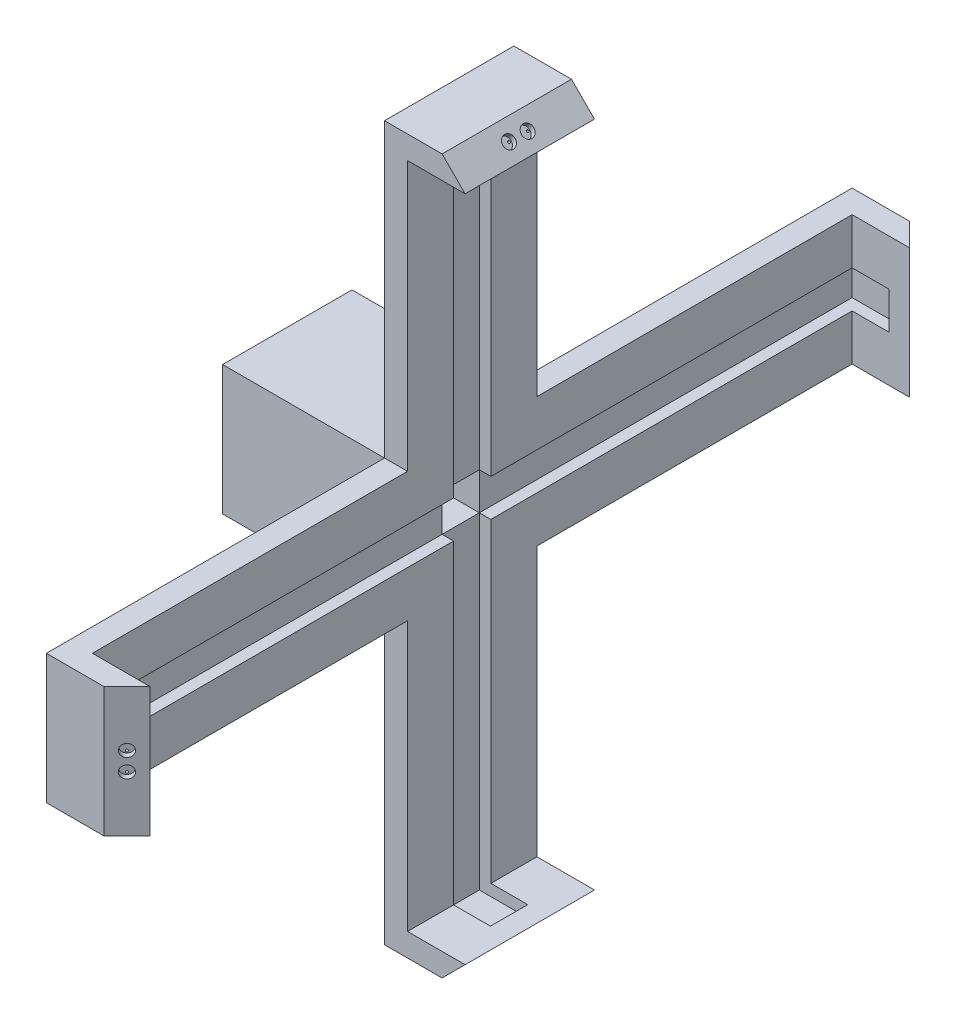
from build123d import *

# Parameters (mm, degrees)
SKETCH1_R            = 28.1
BOSS_EXTRUDE2_DEPTH  = 24
CUT_EXTRUDE2_DEPTH   = 21.5
SKETCH4_R            = 3
CUT_EXTRUDE3_DEPTH   = 9.5
SKETCH6_R            = 6.025
CUT_EXTRUDE4_DEPTH   = 6.2
SKETCH7_W            = 56.2
SKETCH7_H            = 56.2
BOSS_EXTRUDE3_DEPTH  = 56.2
SKETCH8_W            = 56.2
SKETCH8_H            = 56.2
BOSS_EXTRUDE4_DEPTH  = 14.14
SKETCH10_W           = 56.2
SKETCH10_H           = 56.2
BOSS_EXTRUDE5_DEPTH  = 10
SKETCH11_W           = 10
SKETCH11_H           = 56.2
BOSS_EXTRUDE6_DEPTH  = 146.9
SKETCH12_W           = 10
SKETCH12_H           = 56.2
BOSS_EXTRUDE7_DEPTH  = 126.9
SKETCH13_W           = 10
SKETCH13_H           = 56.2
BOSS_EXTRUDE8_DEPTH  = 146.9
SKETCH14_W           = 10
SKETCH14_H           = 56.2
BOSS_EXTRUDE9_DEPTH  = 126.9
SKETCH15_W           = 10
SKETCH15_H           = 56.2
BOSS_EXTRUDE10_DEPTH = 25
SKETCH16_W           = 10
SKETCH16_H           = 56.2
BOSS_EXTRUDE11_DEPTH = 25
SKETCH17_W           = 56.2
SKETCH17_H           = 10
BOSS_EXTRUDE12_DEPTH = 25
SKETCH18_W           = 56.2
SKETCH18_H           = 10
BOSS_EXTRUDE13_DEPTH = 25
SKETCH19_W           = 51.2
SKETCH19_H           = 51.2
CUT_EXTRUDE5_DEPTH   = 63.7
SKETCH23_W           = 330
SKETCH23_H           = 16.2
CUT_EXTRUDE7_DEPTH   = 5
SKETCH24_W           = 16.2
SKETCH24_H           = 290
CUT_EXTRUDE8_DEPTH   = 5
SKETCH25_W           = 16.2
SKETCH25_H           = 16.2
CUT_EXTRUDE12_DEPTH  = 25
CUT_EXTRUDE13_DEPTH  = 56.2
CUT_EXTRUDE14_DEPTH  = 56.2
SKETCH28_W           = 21
SKETCH28_H           = 16.2
CUT_EXTRUDE15_DEPTH  = 5
SKETCH29_W           = 21
SKETCH29_H           = 16.2
CUT_EXTRUDE16_DEPTH  = 5
SKETCH30_W           = 21
SKETCH30_H           = 16.2
CUT_EXTRUDE17_DEPTH  = 5
SKETCH31_W           = 21
SKETCH31_H           = 16.2
CUT_EXTRUDE18_DEPTH  = 5
SKETCH33_R           = 2.65
CUT_EXTRUDE19_DEPTH  = 2.4
SKETCH34_R           = 0.5
CUT_EXTRUDE20_DEPTH  = 10
SKETCH35_R           = 2.65
CUT_EXTRUDE21_DEPTH  = 2.4
SKETCH36_R           = 0.5
CUT_EXTRUDE22_DEPTH  = 10
SKETCH37_R           = 2.65
CUT_EXTRUDE23_DEPTH  = 2.4
SKETCH38_R           = 0.5
CUT_EXTRUDE24_DEPTH  = 10
SKETCH39_R           = 2.65
CUT_EXTRUDE25_DEPTH  = 2.4
SKETCH40_R           = 0.5
CUT_EXTRUDE26_DEPTH  = 10
SKETCH41_R           = 3.75
CUT_EXTRUDE28_DEPTH  = 30


with BuildPart() as part:
    # Sketch1 → Boss-Extrude2 (new body)
    with BuildSketch(Plane.XY):
        Circle(SKETCH1_R)
    extrude(amount=BOSS_EXTRUDE2_DEPTH)

    # Sketch3 → Cut-Extrude2 (cut)
    with BuildSketch(Plane(origin=(0, 0, 0), x_dir=(-1, 0, 0), z_dir=(0, 0, -1))):
        with BuildLine():
            Line((-1.661801922, 2.5), (1.661801922, 2.5))
            ThreePointArc((1.661801922, 2.5), (0, -3.001930317), (-1.661801922, 2.5))
        make_face()
    extrude(amount=-CUT_EXTRUDE2_DEPTH, mode=Mode.SUBTRACT)

    # Sketch4 → Cut-Extrude3 (cut)
    with BuildSketch(Plane(origin=(0, 0, 0), x_dir=(-1, 0, 0), z_dir=(0, 0, -1))):
        Circle(SKETCH4_R)
    extrude(amount=-CUT_EXTRUDE3_DEPTH, mode=Mode.SUBTRACT)

    # Sketch6 → Cut-Extrude4 (cut)
    with BuildSketch(Plane(origin=(0, 0, 0), x_dir=(-1, 0, 0), z_dir=(0, 0, -1))):
        Circle(SKETCH6_R)
    extrude(amount=-CUT_EXTRUDE4_DEPTH, mode=Mode.SUBTRACT)

    # Sketch7 → Boss-Extrude3 (add)
    with BuildSketch(Plane.XY.offset(24)):
        Rectangle(SKETCH7_W, SKETCH7_H)
    extrude(amount=BOSS_EXTRUDE3_DEPTH)

    # Sketch8 → Boss-Extrude4 (add)
    with BuildSketch(Plane(origin=(28.1, 0, 0), x_dir=(0, 0, -1), z_dir=(1, 0, 0))):
        with Locations((-52.1, 0)):
            Rectangle(SKETCH8_W, SKETCH8_H)
    extrude(amount=BOSS_EXTRUDE4_DEPTH)

    # Sketch10 → Boss-Extrude5 (add)
    with BuildSketch(Plane(origin=(42.24, 0, 0), x_dir=(0, 0, -1), z_dir=(1, 0, 0))):
        with Locations((-52.1, 0)):
            Rectangle(SKETCH10_W, SKETCH10_H)
    extrude(amount=BOSS_EXTRUDE5_DEPTH)

    # Sketch11 → Boss-Extrude6 (add)
    with BuildSketch(Plane.XY.offset(80.2)):
        with Locations((47.24, 0)):
            Rectangle(SKETCH11_W, SKETCH11_H)
    extrude(amount=BOSS_EXTRUDE6_DEPTH)

    # Sketch12 → Boss-Extrude7 (add)
    with BuildSketch(Plane(origin=(0, 28.1, 0), x_dir=(1, 0, 0), z_dir=(0, 1, 0))):
        with Locations((47.24, -52.1)):
            Rectangle(SKETCH12_W, SKETCH12_H)
    extrude(amount=BOSS_EXTRUDE7_DEPTH)

    # Sketch13 → Boss-Extrude8 (add)
    with BuildSketch(Plane(origin=(0, 0, 24), x_dir=(-1, 0, 0), z_dir=(0, 0, -1))):
        with Locations((-47.24, 0)):
            Rectangle(SKETCH13_W, SKETCH13_H)
    extrude(amount=BOSS_EXTRUDE8_DEPTH)

    # Sketch14 → Boss-Extrude9 (add)
    with BuildSketch(Plane(origin=(0, -28.1, 0), x_dir=(-1, 0, 0), z_dir=(0, -1, 0))):
        with Locations((-47.24, -52.1)):
            Rectangle(SKETCH14_W, SKETCH14_H)
    extrude(amount=BOSS_EXTRUDE9_DEPTH)

    # Sketch15 → Boss-Extrude10 (add)
    with BuildSketch(Plane(origin=(52.24, 0, 0), x_dir=(0, 0, -1), z_dir=(1, 0, 0))):
        with Locations((-222.1, 0)):
            Rectangle(SKETCH15_W, SKETCH15_H)
    extrude(amount=BOSS_EXTRUDE10_DEPTH)

    # Sketch16 → Boss-Extrude11 (add)
    with BuildSketch(Plane(origin=(52.24, 0, 0), x_dir=(0, 0, -1), z_dir=(1, 0, 0))):
        with Locations((117.9, 0)):
            Rectangle(SKETCH16_W, SKETCH16_H)
    extrude(amount=BOSS_EXTRUDE11_DEPTH)

    # Sketch17 → Boss-Extrude12 (add)
    with BuildSketch(Plane(origin=(52.24, 0, 0), x_dir=(0, 0, -1), z_dir=(1, 0, 0))):
        with Locations((-52.1, 150)):
            Rectangle(SKETCH17_W, SKETCH17_H)
    extrude(amount=BOSS_EXTRUDE12_DEPTH)

    # Sketch18 → Boss-Extrude13 (add)
    with BuildSketch(Plane(origin=(52.24, 0, 0), x_dir=(0, 0, -1), z_dir=(1, 0, 0))):
        with Locations((-52.1, -150)):
            Rectangle(SKETCH18_W, SKETCH18_H)
    extrude(amount=BOSS_EXTRUDE13_DEPTH)

    # Sketch19 → Cut-Extrude5 (cut)
    with BuildSketch(Plane.ZY.offset(28.1)):
        with Locations((52.1, 0)):
            Rectangle(SKETCH19_W, SKETCH19_H)
    extrude(amount=-CUT_EXTRUDE5_DEPTH, mode=Mode.SUBTRACT)

    # Cut-Sweep2: sweep along a path in Sketch20
    with BuildLine(Plane(origin=(0, 0, 0), x_dir=(-1, 0, 0), z_dir=(0, 0, -1))) as cut_sweep2_path:
        ThreePointArc((0, 15), (-10.606601718, 10.606601718), (-15, 0))
    # 3DSketch2 → Cut-Sweep2 (sweep, cut)
    with BuildSketch(Plane(origin=(0, 15, 0), x_dir=(0, 0.17521220324553322, 0.9845306921746249), z_dir=(-1, 0, 0))):
        Polygon((0, 0), (1.314091524, 7.383980191), (42.805237655, 0), (41.491146131, -7.383980191), align=None)
    sweep(path=cut_sweep2_path.line, mode=Mode.SUBTRACT)

    # Sketch23 → Cut-Extrude7 (cut)
    with BuildSketch(Plane(origin=(52.24, 0, 0), x_dir=(0, 0, -1), z_dir=(1, 0, 0))):
        with Locations((-52.1, 0)):
            Rectangle(SKETCH23_W, SKETCH23_H)
    extrude(amount=-CUT_EXTRUDE7_DEPTH, mode=Mode.SUBTRACT)

    # Sketch24 → Cut-Extrude8 (cut)
    with BuildSketch(Plane(origin=(52.24, 0, 0), x_dir=(0, 0, -1), z_dir=(1, 0, 0))):
        with Locations((-52.1, 0)):
            Rectangle(SKETCH24_W, SKETCH24_H)
    extrude(amount=-CUT_EXTRUDE8_DEPTH, mode=Mode.SUBTRACT)

    # Sketch25 → Cut-Extrude12 (cut)
    with BuildSketch(Plane(origin=(47.24, 0, 0), x_dir=(0, 0, -1), z_dir=(1, 0, 0))):
        with Locations((-52.1, 0)):
            Rectangle(SKETCH25_W, SKETCH25_H)
    extrude(amount=-CUT_EXTRUDE12_DEPTH, mode=Mode.SUBTRACT)

    # Sketch26 → Cut-Extrude13 (cut)
    with BuildSketch(Plane(origin=(0, -28.1, 0), x_dir=(-1, 0, 0), z_dir=(0, -1, 0))):
        Polygon((-77.24, -217.1), (-67.24, -227.1), (-77.24, -227.1), align=None)
        Polygon((-77.24, 112.9), (-67.24, 122.9), (-77.24, 122.9), align=None)
    extrude(amount=-CUT_EXTRUDE13_DEPTH, mode=Mode.SUBTRACT)

    # Sketch27 → Cut-Extrude14 (cut)
    with BuildSketch(Plane.XY.offset(80.2)):
        Polygon((77.24, -145), (67.24, -155), (77.24, -155), align=None)
        Polygon((77.24, 145), (67.24, 155), (77.24, 155), align=None)
    extrude(amount=-CUT_EXTRUDE14_DEPTH, mode=Mode.SUBTRACT)

    # Sketch28 → Cut-Extrude15 (cut)
    with BuildSketch(Plane(origin=(0, -145, 0), x_dir=(1, 0, 0), z_dir=(0, 1, 0))):
        with Locations((57.74, -52.1)):
            Rectangle(SKETCH28_W, SKETCH28_H)
    extrude(amount=-CUT_EXTRUDE15_DEPTH, mode=Mode.SUBTRACT)

    # Sketch29 → Cut-Extrude16 (cut)
    with BuildSketch(Plane(origin=(0, 145, 0), x_dir=(-1, 0, 0), z_dir=(0, -1, 0))):
        with Locations((-57.74, -52.1)):
            Rectangle(SKETCH29_W, SKETCH29_H)
    extrude(amount=-CUT_EXTRUDE16_DEPTH, mode=Mode.SUBTRACT)

    # Sketch30 → Cut-Extrude17 (cut)
    with BuildSketch(Plane(origin=(0, 0, 217.1), x_dir=(-1, 0, 0), z_dir=(0, 0, -1))):
        with Locations((-57.74, 0)):
            Rectangle(SKETCH30_W, SKETCH30_H)
    extrude(amount=-CUT_EXTRUDE17_DEPTH, mode=Mode.SUBTRACT)

    # Sketch31 → Cut-Extrude18 (cut)
    with BuildSketch(Plane.XY.offset(-112.9)):
        with Locations((57.74, 0)):
            Rectangle(SKETCH31_W, SKETCH31_H)
    extrude(amount=-CUT_EXTRUDE18_DEPTH, mode=Mode.SUBTRACT)

    # Sketch33 → Cut-Extrude19 (cut)
    with BuildSketch(Plane(origin=(147.17, 0, 147.17), x_dir=(0.7071067811865558, 0, -0.7071067811865392), z_dir=(0.7071067811865392, 0, 0.7071067811865558))):
        with Locations((-105.967022229, 4.05)):
            Circle(SKETCH33_R)
        with Locations((-105.967022229, -4.05)):
            Circle(SKETCH33_R)
    extrude(amount=-CUT_EXTRUDE19_DEPTH, mode=Mode.SUBTRACT)

    # Sketch34 → Cut-Extrude20 (cut)
    with BuildSketch(Plane(origin=(145.472943725, 0, 145.472943725), x_dir=(0.7071067811865559, 0, -0.7071067811865392), z_dir=(0.7071067811865392, 0, 0.7071067811865559))):
        with Locations((-105.967022229, 5.75)):
            Circle(SKETCH34_R)
        with Locations((-105.967022229, 2.35)):
            Circle(SKETCH34_R)
        with Locations((-105.967022229, -2.35)):
            Circle(SKETCH34_R)
        with Locations((-105.967022229, -5.75)):
            Circle(SKETCH34_R)
    extrude(amount=-CUT_EXTRUDE20_DEPTH, mode=Mode.SUBTRACT)

    # Sketch35 → Cut-Extrude21 (cut)
    with BuildSketch(Plane(origin=(95.07, 0, -95.07), x_dir=(-0.7071067811865392, 0, -0.7071067811865559), z_dir=(0.7071067811865559, 0, -0.7071067811865392))):
        with Locations((32.286495629, -4.05)):
            Circle(SKETCH35_R)
        with Locations((32.286495629, 4.05)):
            Circle(SKETCH35_R)
    extrude(amount=-CUT_EXTRUDE21_DEPTH, mode=Mode.SUBTRACT)

    # Sketch36 → Cut-Extrude22 (cut)
    with BuildSketch(Plane(origin=(93.372943725, 0, -93.372943725), x_dir=(-0.7071067811865392, 0, -0.7071067811865558), z_dir=(0.7071067811865558, 0, -0.7071067811865392))):
        with Locations((32.286495629, -5.75)):
            Circle(SKETCH36_R)
        with Locations((32.286495629, -2.35)):
            Circle(SKETCH36_R)
        with Locations((32.286495629, 2.35)):
            Circle(SKETCH36_R)
        with Locations((32.286495629, 5.75)):
            Circle(SKETCH36_R)
    extrude(amount=-CUT_EXTRUDE22_DEPTH, mode=Mode.SUBTRACT)

    # Sketch37 → Cut-Extrude23 (cut)
    with BuildSketch(Plane(origin=(111.12, -111.12, 0), x_dir=(0, 0, -1), z_dir=(0.707106781186554, -0.7071067811865411, 0))):
        with Locations(Location((-56.15, -54.984623305, 0), (0, 0, 90))):
            Circle(SKETCH37_R)
        with Locations(Location((-48.05, -54.984623305, 0), (0, 0, 90))):
            Circle(SKETCH37_R)
    extrude(amount=-CUT_EXTRUDE23_DEPTH, mode=Mode.SUBTRACT)

    # Sketch38 → Cut-Extrude24 (cut)
    with BuildSketch(Plane(origin=(109.422943725, -109.422943725, 0), x_dir=(0, 0, -1), z_dir=(0.7071067811865539, -0.7071067811865411, 0))):
        with Locations(Location((-57.85, -54.984623305, 0), (0, 0, 90))):
            Circle(SKETCH38_R)
        with Locations(Location((-54.45, -54.984623305, 0), (0, 0, 90))):
            Circle(SKETCH38_R)
        with Locations(Location((-49.75, -54.984623305, 0), (0, 0, 90))):
            Circle(SKETCH38_R)
        with Locations(Location((-46.35, -54.984623305, 0), (0, 0, 90))):
            Circle(SKETCH38_R)
    extrude(amount=-CUT_EXTRUDE24_DEPTH, mode=Mode.SUBTRACT)

    # Sketch39 → Cut-Extrude25 (cut)
    with BuildSketch(Plane(origin=(111.12, 111.12, 0), x_dir=(0.707106781186554, -0.7071067811865411, 0), z_dir=(0.7071067811865411, 0.707106781186554, 0))):
        with Locations(Location((-54.984623305, -48.05, 0), (0, 0, 180))):
            Circle(SKETCH39_R)
        with Locations(Location((-54.984623305, -56.15, 0), (0, 0, 180))):
            Circle(SKETCH39_R)
    extrude(amount=-CUT_EXTRUDE25_DEPTH, mode=Mode.SUBTRACT)

    # Sketch40 → Cut-Extrude26 (cut)
    with BuildSketch(Plane(origin=(109.422943725, 109.422943725, 0), x_dir=(0.7071067811865539, -0.7071067811865411, 0), z_dir=(0.7071067811865411, 0.7071067811865539, 0))):
        with Locations(Location((-54.984623305, -46.35, 0), (0, 0, 180))):
            Circle(SKETCH40_R)
        with Locations(Location((-54.984623305, -49.75, 0), (0, 0, 180))):
            Circle(SKETCH40_R)
        with Locations(Location((-54.984623305, -54.45, 0), (0, 0, 180))):
            Circle(SKETCH40_R)
        with Locations(Location((-54.984623305, -57.85, 0), (0, 0, 180))):
            Circle(SKETCH40_R)
    extrude(amount=-CUT_EXTRUDE26_DEPTH, mode=Mode.SUBTRACT)

    # Sketch41 → Cut-Extrude28 (cut)
    with BuildSketch(Plane(origin=(0, 0, 0), x_dir=(-1, 0, 0), z_dir=(0, 0, -1))):
        with Locations((0, 18.75)):
            Circle(SKETCH41_R)
        with Locations((-18.75, 0)):
            Circle(SKETCH41_R)
    extrude(amount=-CUT_EXTRUDE28_DEPTH, mode=Mode.SUBTRACT)


solid = part.part
